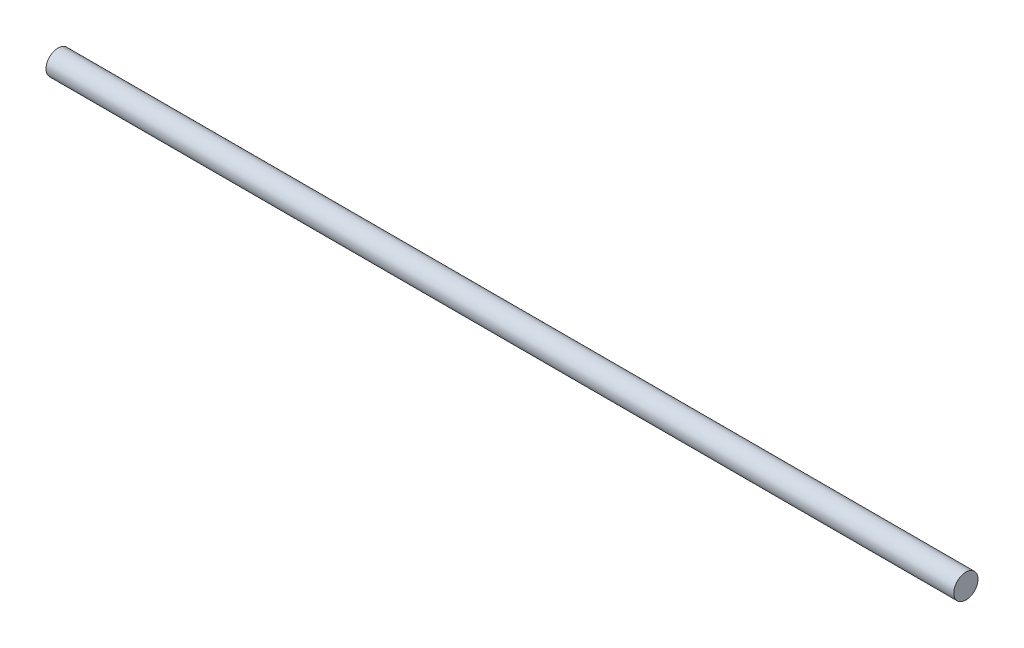
from build123d import *

# Parameters (mm, degrees)
SKETCH1_R           = 4
BOSS_EXTRUDE1_DEPTH = 300


with BuildPart() as part:
    # Sketch1 → Boss-Extrude1 (new body)
    with BuildSketch(Plane(origin=(0, 0, 0), x_dir=(0, 0, -1), z_dir=(1, 0, 0))):
        Circle(SKETCH1_R)
    extrude(amount=BOSS_EXTRUDE1_DEPTH)


solid = part.part
